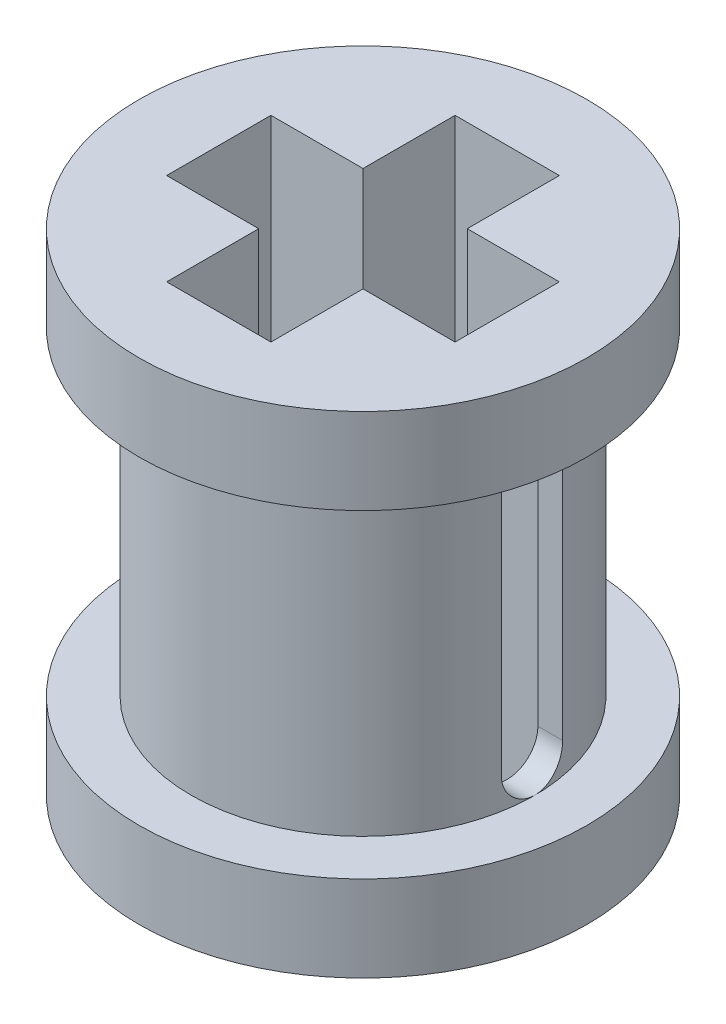
from build123d import *

# Parameters (mm, degrees)
SKETCH2_R           = 3.65
BOSS_EXTRUDE1_DEPTH = 1.4
SKETCH3_R           = 2.8
BOSS_EXTRUDE2_DEPTH = 5.2
SKETCH4_R           = 3.65
BOSS_EXTRUDE3_DEPTH = 1.4
CUT_EXTRUDE1_DEPTH  = 9
CUT_EXTRUDE2_DEPTH  = 14.65


with BuildPart() as part:
    # Sketch2 → Boss-Extrude1 (new body)
    with BuildSketch(Plane(origin=(0, 0, 0), x_dir=(1, 0, 0), z_dir=(0, 1, 0))):
        Circle(SKETCH2_R)
    extrude(amount=BOSS_EXTRUDE1_DEPTH)

    # Sketch3 → Boss-Extrude2 (add)
    with BuildSketch(Plane(origin=(0, 1.4, 0), x_dir=(1, 0, 0), z_dir=(0, 1, 0))):
        Circle(SKETCH3_R)
    extrude(amount=BOSS_EXTRUDE2_DEPTH)

    # Sketch4 → Boss-Extrude3 (add)
    with BuildSketch(Plane(origin=(0, 6.6, 0), x_dir=(1, 0, 0), z_dir=(0, 1, 0))):
        Circle(SKETCH4_R)
    extrude(amount=BOSS_EXTRUDE3_DEPTH)

    # Sketch5 → Cut-Extrude1 (cut, through all)
    with BuildSketch(Plane(origin=(0, 8, 0), x_dir=(1, 0, 0), z_dir=(0, 1, 0))):
        Polygon((0.85, -2.351063589), (0.85, -0.85), (2.351063589, -0.85), (2.351063589, 0.85), (0.85, 0.85), (0.85, 2.351063589), (-0.85, 2.351063589), (-0.85, 0.85), (-2.351063589, 0.85), (-2.351063589, -0.85), (-0.85, -0.85), (-0.85, -2.351063589), align=None)
    extrude(amount=-CUT_EXTRUDE1_DEPTH, mode=Mode.SUBTRACT)

    # Sketch6 → Cut-Extrude2 (cut, through all)
    with BuildSketch(Plane(origin=(10, 0, 0), x_dir=(0, 0, -1), z_dir=(1, 0, 0))):
        with BuildLine():
            Line((0.5, 6.098665366), (0.5, 1.901334634))
            ThreePointArc((0.5, 1.901334634), (0, 1.401334634), (-0.5, 1.901334634))
            Line((-0.5, 1.901334634), (-0.5, 6.098665366))
            ThreePointArc((-0.5, 6.098665366), (0, 6.598665366), (0.5, 6.098665366))
        make_face()
    extrude(amount=-CUT_EXTRUDE2_DEPTH, mode=Mode.SUBTRACT)


solid = part.part
